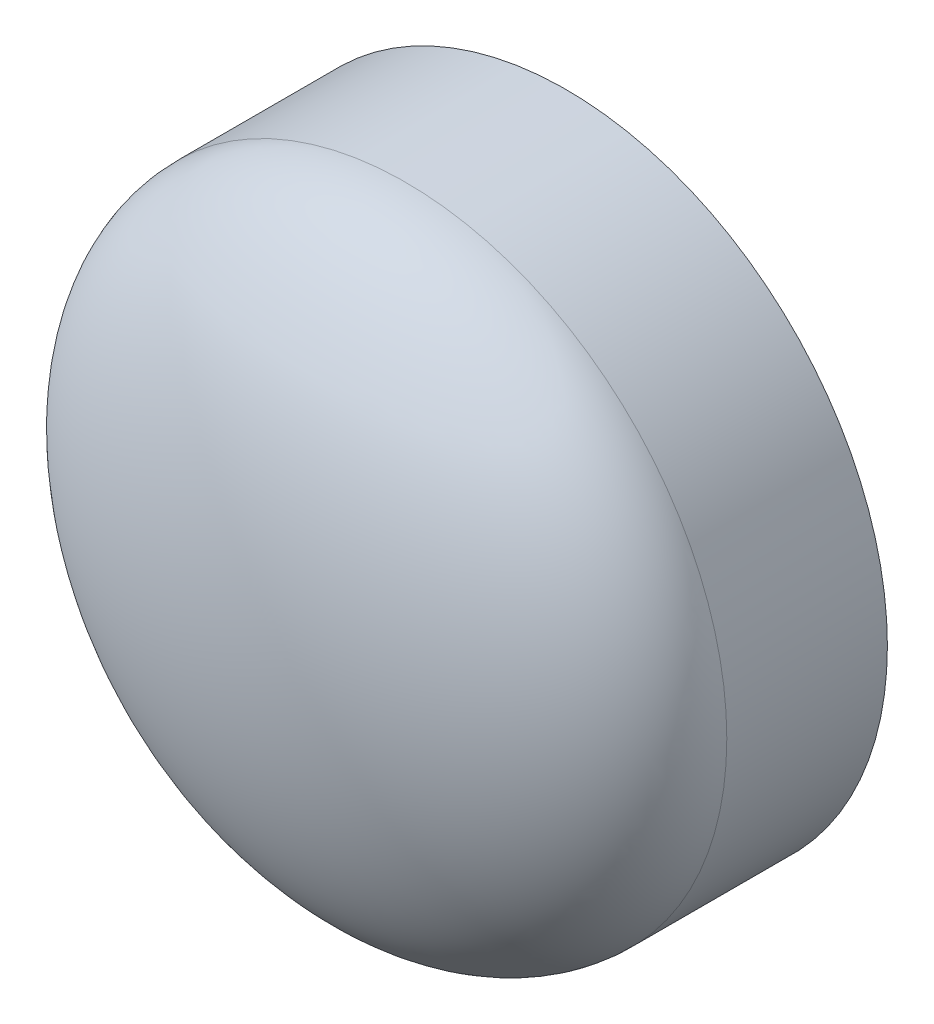
from build123d import *

# Parameters (mm, degrees)
SKETCH1_R           = 1.5875
BOSS_EXTRUDE1_DEPTH = 0.79375
DOME1_FACE_RADIUS   = 1.5875
DOME1_HEIGHT        = 0.79375


with BuildPart() as part:
    # Sketch1 → Boss-Extrude1 (new body)
    with BuildSketch(Plane.XY):
        Circle(SKETCH1_R)
    extrude(amount=BOSS_EXTRUDE1_DEPTH)

    # Dome1: an elliptical dome of height H over a round flat face of radius A is half a spheroid: the quarter ellipse of half axes A and H revolved about the face's axis
    with BuildSketch(Plane((0, 0, 0.79375), x_dir=(0, 1, 0), z_dir=(1, 0, 0)), mode=Mode.PRIVATE) as dome1_quarter:
        Ellipse(DOME1_FACE_RADIUS, DOME1_HEIGHT)
        Rectangle(DOME1_FACE_RADIUS, DOME1_HEIGHT, align=(Align.MIN, Align.MIN), mode=Mode.INTERSECT)
    revolve(dome1_quarter.sketch, axis=Axis((0, 0, 0.79375), (0, 0, 1)))


solid = part.part
